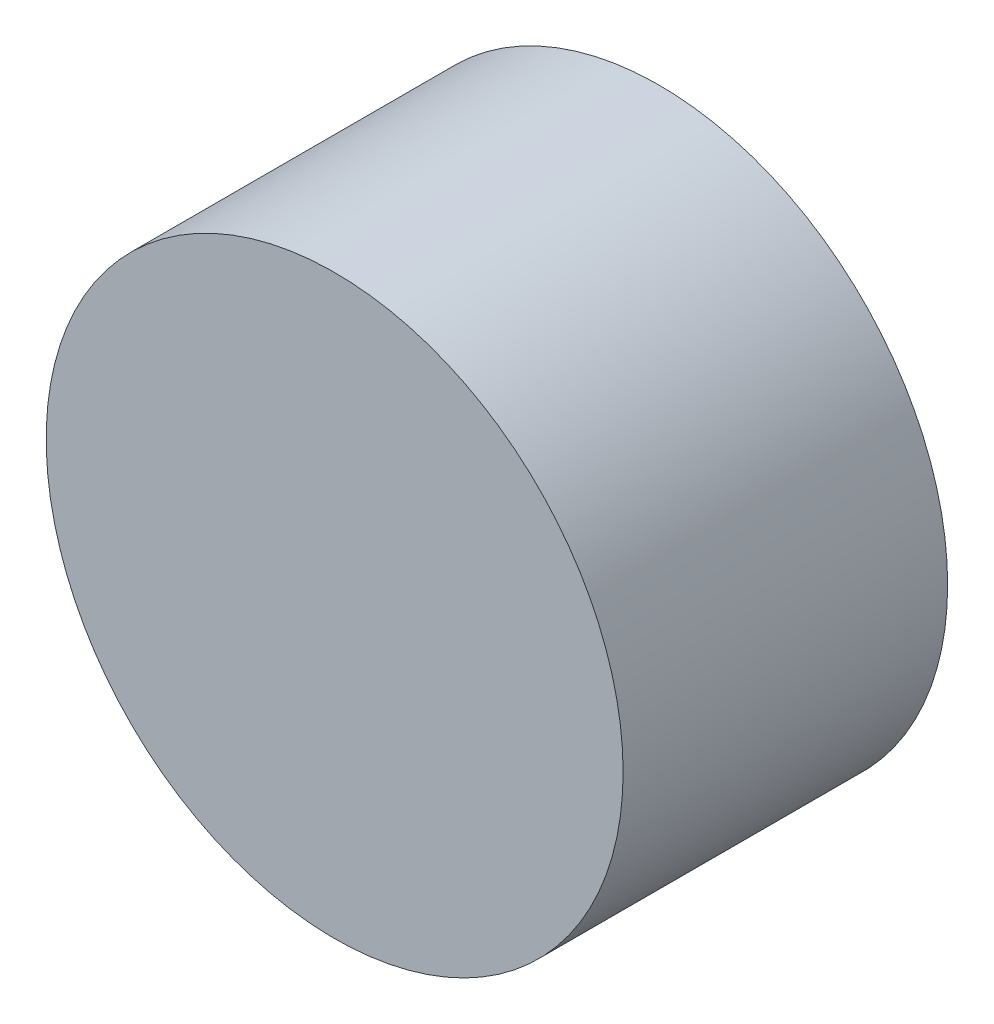
from build123d import *

# Parameters (mm, degrees)
SKETCH1_R           = 32
BOSS_EXTRUDE1_DEPTH = 36


with BuildPart() as part:
    # Sketch1 → Boss-Extrude1 (new body)
    with BuildSketch(Plane.XY):
        Circle(SKETCH1_R)
    extrude(amount=BOSS_EXTRUDE1_DEPTH)


solid = part.part
